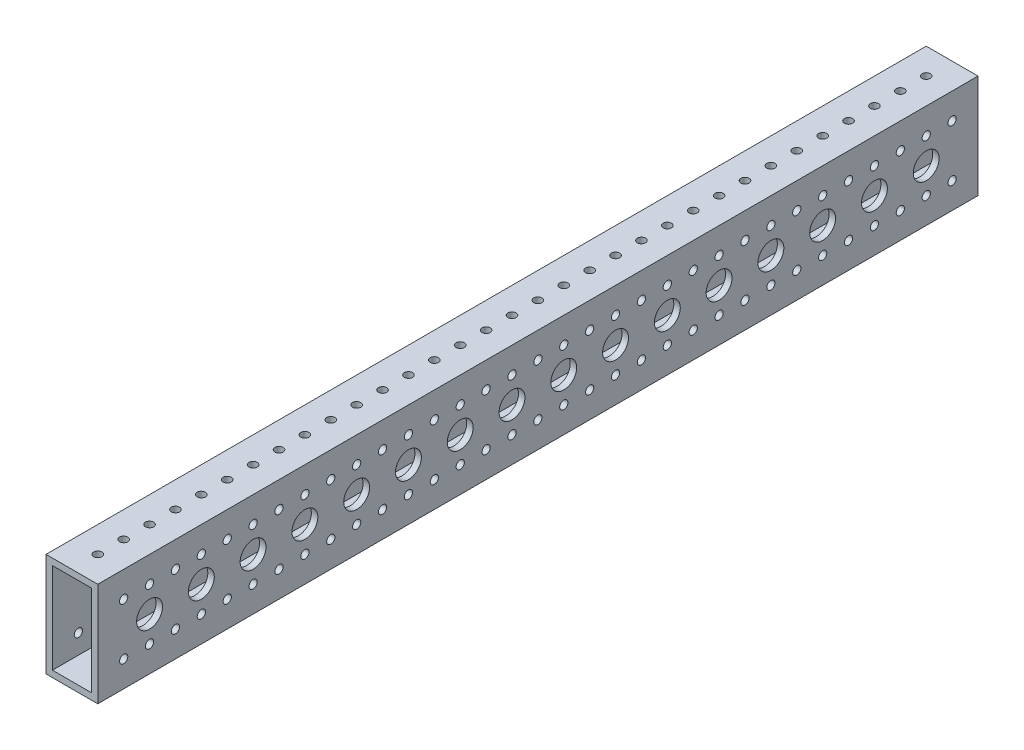
from build123d import *

# Parameters (mm, degrees)
SKETCH1_W                   = 25.4
SKETCH1_H                   = 50.8
SKETCH1_W_2                 = 19.05
SKETCH1_H_2                 = 44.45
BOSS_EXTRUDE1_DEPTH         = 431.8
F_1_2_0_5_DIAMETER_HOLE1_D  = 12.7
LPATTERN1_COUNT             = 16
LPATTERN1_PITCH             = 25.4
F_21_0_159_DIAMETER_HOLE1_D = 4.0386
LPATTERN2_COUNT             = 33
LPATTERN2_PITCH             = 12.7
LPATTERN2_COUNT_DIR2        = 2
LPATTERN2_PITCH_DIR2        = 25.4
F_21_0_159_DIAMETER_HOLE2_D = 4.0386
LPATTERN3_COUNT             = 33
LPATTERN3_PITCH             = 12.7


with BuildPart() as part:
    # Sketch1 → Boss-Extrude1 (new body)
    with BuildSketch(Plane.XY):
        Rectangle(SKETCH1_W, SKETCH1_H)
        Rectangle(SKETCH1_W_2, SKETCH1_H_2, mode=Mode.SUBTRACT)
    extrude(amount=BOSS_EXTRUDE1_DEPTH)

    # 1/2 (0.5) Diameter Hole1 (through all)
    with Locations(Plane.ZY.offset(12.7)):
        with Locations((25.4, 0)):
            f_1_2_0_5_diameter_hole1 = Hole(F_1_2_0_5_DIAMETER_HOLE1_D / 2)

    # LPattern1: 1/2 (0.5) Diameter Hole1 ×16
    with Locations(*[(0, 0, i * LPATTERN1_PITCH) for i in range(1, LPATTERN1_COUNT)]):
        add(f_1_2_0_5_diameter_hole1, mode=Mode.SUBTRACT)

    # #21 (0.159) Diameter Hole1 (through all)
    with Locations(Plane.ZY.offset(12.7)):
        with Locations((12.7, 12.7)):
            f_21_0_159_diameter_hole1 = Hole(F_21_0_159_DIAMETER_HOLE1_D / 2)

    # LPattern2: 21 _0.159_ Diameter Hole1 33 × 2
    with Locations(*[(0, -j * LPATTERN2_PITCH_DIR2, i * LPATTERN2_PITCH) for i in range(LPATTERN2_COUNT) for j in range(LPATTERN2_COUNT_DIR2) if (i, j) != (0, 0)]):
        add(f_21_0_159_diameter_hole1, mode=Mode.SUBTRACT)

    # #21 (0.159) Diameter Hole2 (through all)
    with Locations(Plane(origin=(0, 25.4, 0), x_dir=(1, 0, 0), z_dir=(0, 1, 0))):
        with Locations((0, -12.7)):
            f_21_0_159_diameter_hole2 = Hole(F_21_0_159_DIAMETER_HOLE2_D / 2)

    # LPattern3: #21 (0.159) Diameter Hole2 ×33
    with Locations(*[(0, 0, i * LPATTERN3_PITCH) for i in range(1, LPATTERN3_COUNT)]):
        add(f_21_0_159_diameter_hole2, mode=Mode.SUBTRACT)


solid = part.part
